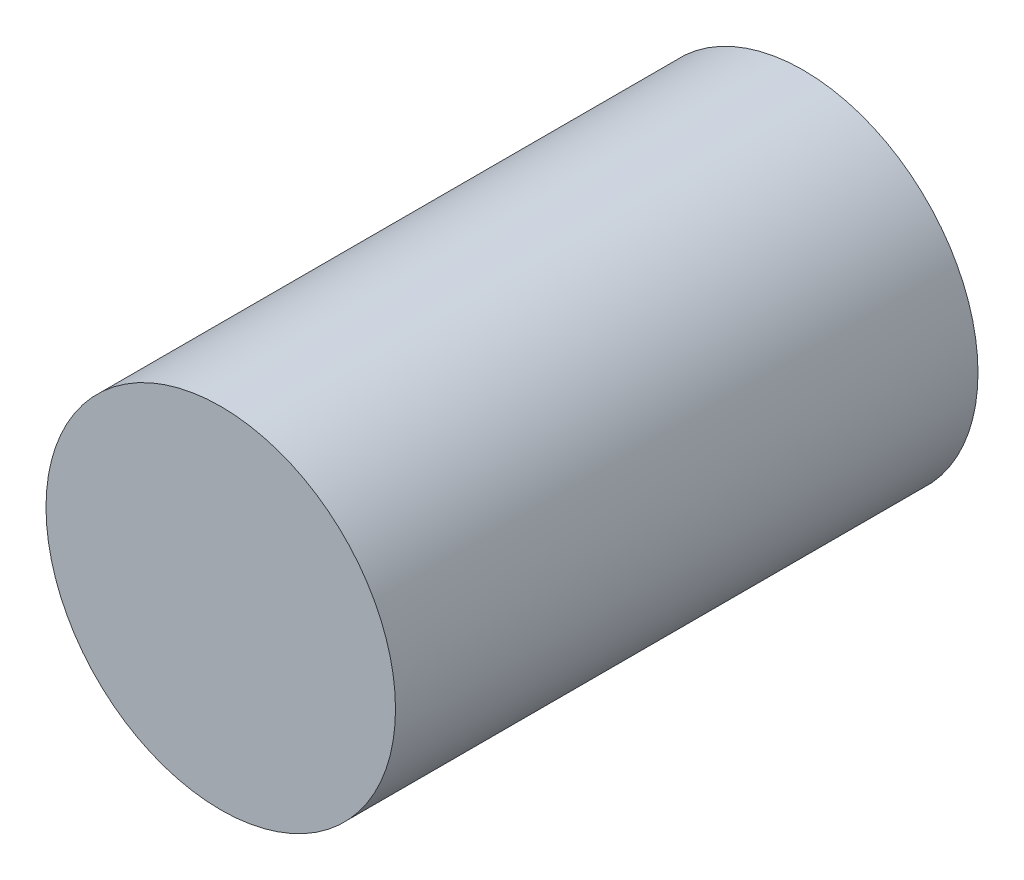
from build123d import *

# Parameters (mm, degrees)
SKETCH1_R           = 1.5
BOSS_EXTRUDE1_DEPTH = 5


with BuildPart() as part:
    # Sketch1 → Boss-Extrude1 (new body)
    with BuildSketch(Plane.XY):
        with Locations((181.071886603, 170.669160633)):
            Circle(SKETCH1_R)
    extrude(amount=-BOSS_EXTRUDE1_DEPTH)


solid = part.part
